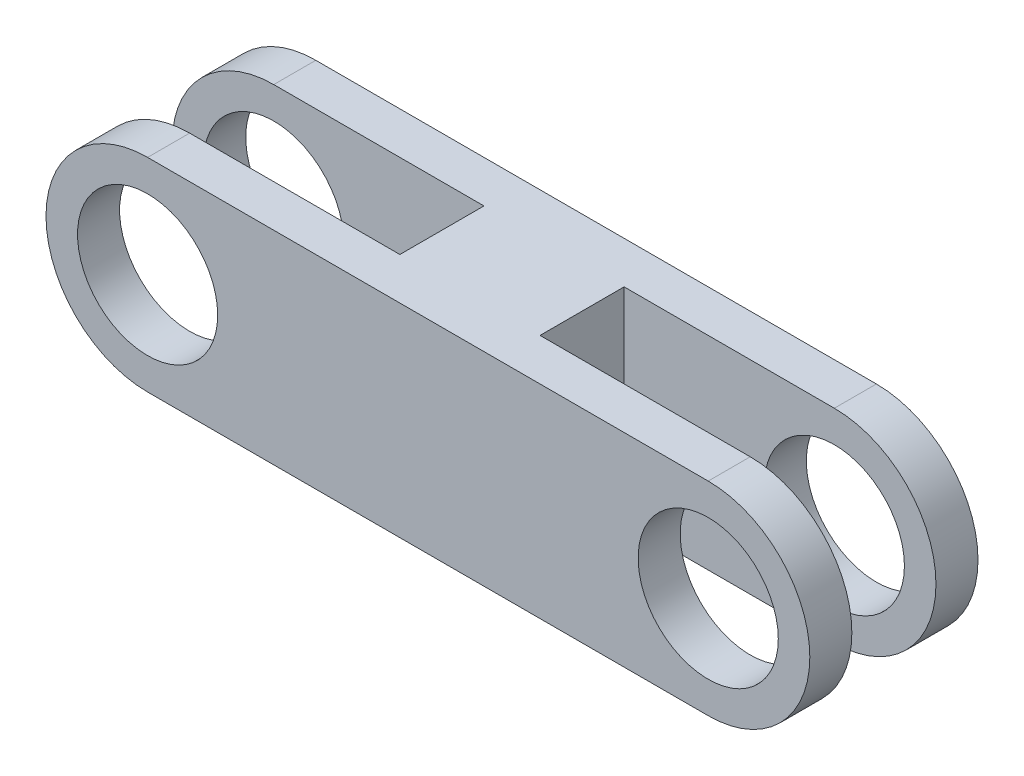
from build123d import *

# Parameters (mm, degrees)
SKETCH1_R           = 10
BOSS_EXTRUDE1_DEPTH = 6
BOSS_EXTRUDE2_START = -18
SKETCH1_2_R         = 10
BOSS_EXTRUDE2_DEPTH = 6
SKETCH4_W           = 20
SKETCH4_H           = 24
BOSS_EXTRUDE3_DEPTH = 29


with BuildPart() as part:
    # Sketch1 → Boss-Extrude1 (new body)
    with BuildSketch(Plane.XY):
        with BuildLine():
            Line((40, -14.5), (-40, -14.5))
            ThreePointArc((-40, -14.5), (-54.5, 0), (-40, 14.5))
            Line((-40, 14.5), (40, 14.5))
            ThreePointArc((40, 14.5), (54.5, 0), (40, -14.5))
        make_face()
        with Locations((-40, 0)):
            Circle(SKETCH1_R, mode=Mode.SUBTRACT)
        with Locations((40, 0)):
            Circle(SKETCH1_R, mode=Mode.SUBTRACT)
    extrude(amount=BOSS_EXTRUDE1_DEPTH)



with BuildPart() as body_2:
    # Sketch1_2 → Boss-Extrude2 (new body)
    with BuildSketch(Plane.XY.offset(BOSS_EXTRUDE2_START)):
        with BuildLine():
            Line((40, -14.5), (-40, -14.5))
            ThreePointArc((-40, -14.5), (-54.5, 0), (-40, 14.5))
            Line((-40, 14.5), (40, 14.5))
            ThreePointArc((40, 14.5), (54.5, 0), (40, -14.5))
        make_face()
        with Locations((-40, 0)):
            Circle(SKETCH1_2_R, mode=Mode.SUBTRACT)
        with Locations((40, 0)):
            Circle(SKETCH1_2_R, mode=Mode.SUBTRACT)
    extrude(amount=BOSS_EXTRUDE2_DEPTH)


with BuildPart() as part_1:
    add(part.part)

    add(body_2.part)  # Boss-Extrude3 merges body 2
    # Sketch4 → Boss-Extrude3 (add)
    with BuildSketch(Plane(origin=(0, 14.5, 0), x_dir=(1, 0, 0), z_dir=(0, 1, 0))):
        with Locations((0, 6)):
            Rectangle(SKETCH4_W, SKETCH4_H)
    extrude(amount=-BOSS_EXTRUDE3_DEPTH)


solid = part_1.part
